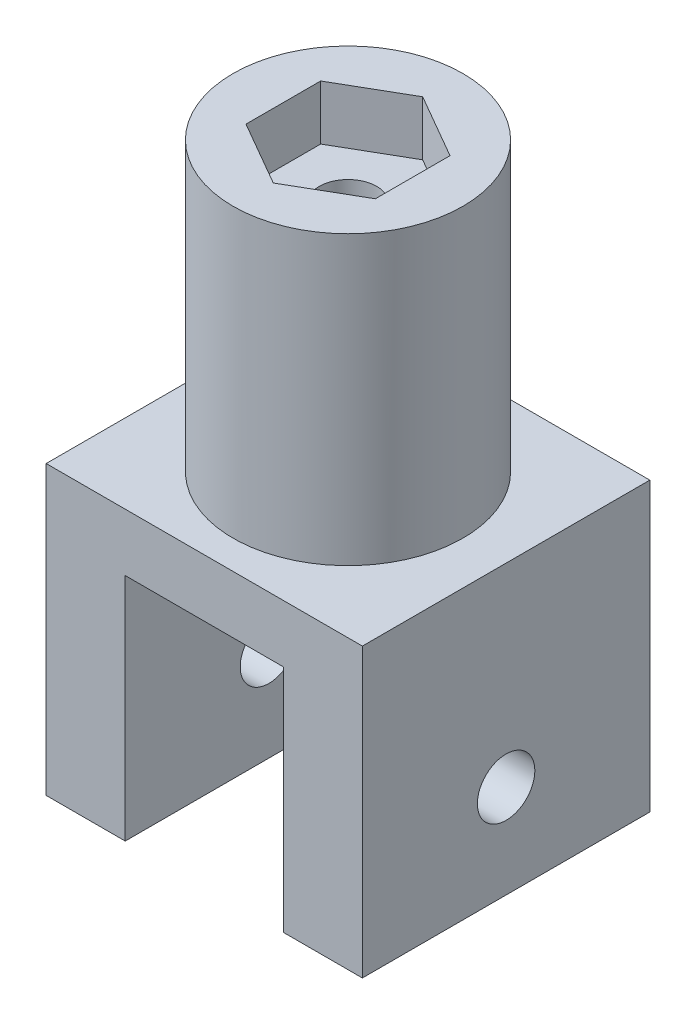
from build123d import *

# Parameters (mm, degrees)
SKETCH1_R           = 6.5
SKETCH1_R_2         = 2
BOSS_EXTRUDE1_DEPTH = 20
SKETCH6_W           = 22
SKETCH6_H           = 20
BOSS_EXTRUDE2_DEPTH = 4
SKETCH7_W           = 5.5
SKETCH7_H           = 20
BOSS_EXTRUDE3_DEPTH = 20
SKETCH8_R           = 2
CUT_EXTRUDE1_DEPTH  = 23
SKETCH14_R          = 8
SKETCH14_R_2        = 6.5
BOSS_EXTRUDE4_DEPTH = 20
CUT_EXTRUDE2_DEPTH  = 3.8
SKETCH16_R          = 2
CUT_EXTRUDE3_DEPTH  = 21


with BuildPart() as part:
    # Sketch1 → Boss-Extrude1 (new body)
    with BuildSketch(Plane(origin=(0, 0, 0), x_dir=(1, 0, 0), z_dir=(0, 1, 0))):
        Circle(SKETCH1_R)
        Circle(SKETCH1_R_2, mode=Mode.SUBTRACT)
    extrude(amount=BOSS_EXTRUDE1_DEPTH)

    # Sketch6 → Boss-Extrude2 (add)
    with BuildSketch(Plane.XZ):
        Rectangle(SKETCH6_W, SKETCH6_H)
    extrude(amount=BOSS_EXTRUDE2_DEPTH)

    # Sketch7 → Boss-Extrude3 (add)
    with BuildSketch(Plane.XY.offset(10)):
        with Locations((8.25, -10)):
            Rectangle(SKETCH7_W, SKETCH7_H)
        with Locations((-8.25, -10)):
            Rectangle(SKETCH7_W, SKETCH7_H)
    extrude(amount=-BOSS_EXTRUDE3_DEPTH)

    # Sketch8 → Cut-Extrude1 (cut, through all)
    with BuildSketch(Plane(origin=(11, 0, 0), x_dir=(0, 0, -1), z_dir=(1, 0, 0))):
        with Locations((0, -13.5)):
            Circle(SKETCH8_R)
    extrude(amount=-CUT_EXTRUDE1_DEPTH, mode=Mode.SUBTRACT)

    # Sketch14 → Boss-Extrude4 (add)
    with BuildSketch(Plane(origin=(0, 0, 0), x_dir=(1, 0, 0), z_dir=(0, 1, 0))):
        Circle(SKETCH14_R)
        Circle(SKETCH14_R_2, mode=Mode.SUBTRACT)
    extrude(amount=BOSS_EXTRUDE4_DEPTH)

    # Sketch15 → Cut-Extrude2 (cut)
    with BuildSketch(Plane(origin=(0, 20, 0), x_dir=(1, 0, 0), z_dir=(0, 1, 0))):
        Polygon((4.5, 2.598076211), (0, 5.196152423), (-4.5, 2.598076211), (-4.5, -2.598076211), (0, -5.196152423), (4.5, -2.598076211), align=None)
    extrude(amount=-CUT_EXTRUDE2_DEPTH, mode=Mode.SUBTRACT)

    # Sketch16 → Cut-Extrude3 (cut, through all)
    with BuildSketch(Plane(origin=(0, 0, 0), x_dir=(1, 0, 0), z_dir=(0, 1, 0))):
        Circle(SKETCH16_R)
    extrude(amount=-CUT_EXTRUDE3_DEPTH, mode=Mode.SUBTRACT)


solid = part.part
